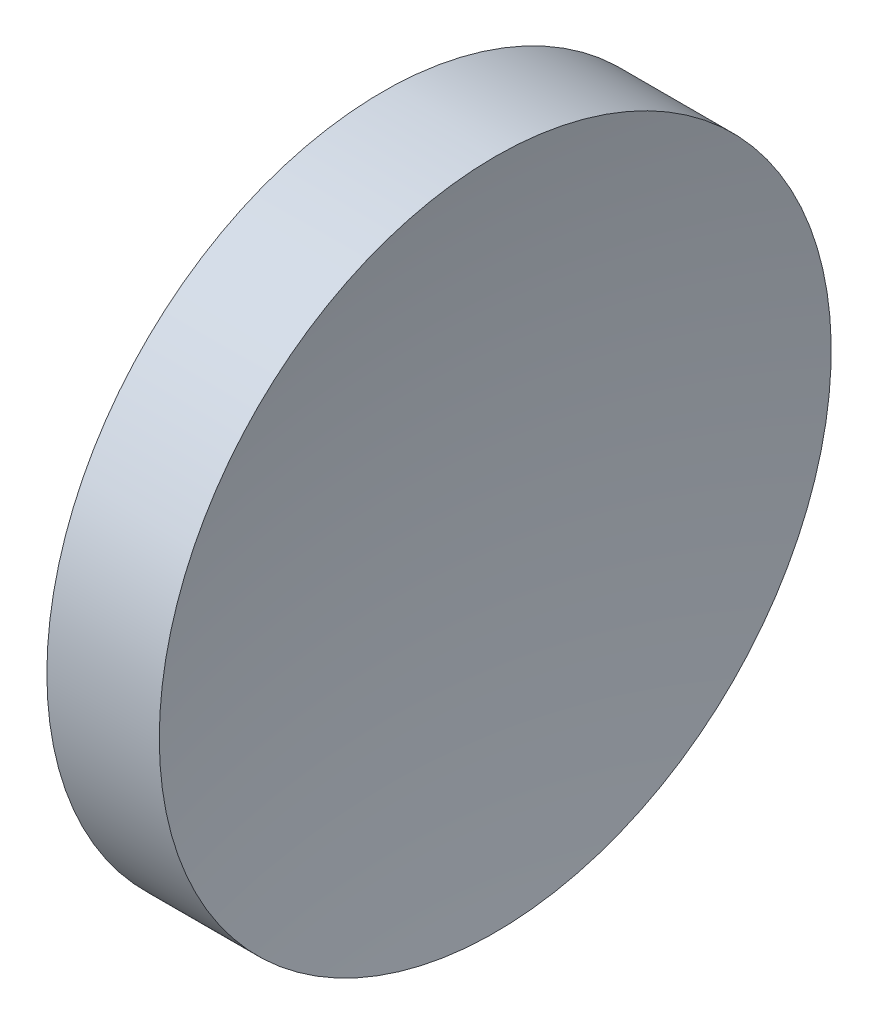
from build123d import *


with BuildPart() as part:
    # 草图1 → 旋转1 (revolve)
    with BuildSketch(Plane.XY):
        with BuildLine():
            Line((230.199611905, 138.756042247), (230.199611905, 176.256042247))
            Line((230.199611905, 176.256042247), (242.746691363, 176.256042247))
            ThreePointArc((242.746691363, 176.256042247), (240.088356456, 157.589733949), (239.199611931, 138.756042247))
            Line((239.199611931, 138.756042247), (230.199611905, 138.756042247))
        make_face()
    revolve(axis=Axis((217.970286004, 138.756042247, 0), (1, 0, 0)))


solid = part.part
